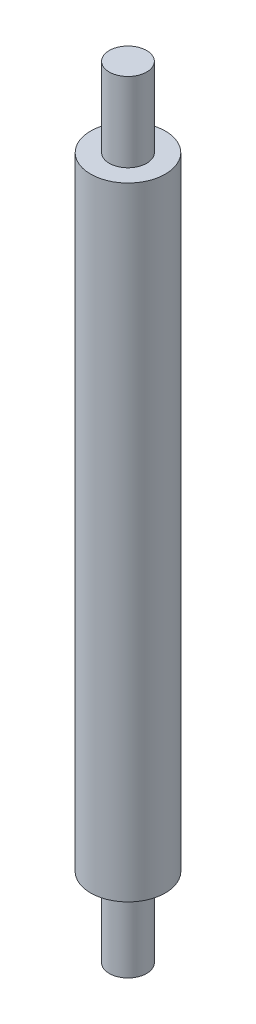
from build123d import *

# Parameters (mm, degrees)
SKETCH1_R           = 1.5
BOSS_EXTRUDE1_DEPTH = 6.35
SKETCH2_R           = 3
BOSS_EXTRUDE2_DEPTH = 50
SKETCH3_R           = 1.5
BOSS_EXTRUDE3_DEPTH = 6.35


with BuildPart() as part:
    # Sketch1 → Boss-Extrude1 (new body)
    with BuildSketch(Plane(origin=(0, 0, 0), x_dir=(1, 0, 0), z_dir=(0, 1, 0))):
        Circle(SKETCH1_R)
    extrude(amount=BOSS_EXTRUDE1_DEPTH)

    # Sketch2 → Boss-Extrude2 (add)
    with BuildSketch(Plane(origin=(0, 6.35, 0), x_dir=(1, 0, 0), z_dir=(0, 1, 0))):
        Circle(SKETCH2_R)
    extrude(amount=BOSS_EXTRUDE2_DEPTH)

    # Sketch3 → Boss-Extrude3 (add)
    with BuildSketch(Plane(origin=(0, 56.35, 0), x_dir=(1, 0, 0), z_dir=(0, 1, 0))):
        Circle(SKETCH3_R)
    extrude(amount=BOSS_EXTRUDE3_DEPTH)


solid = part.part
